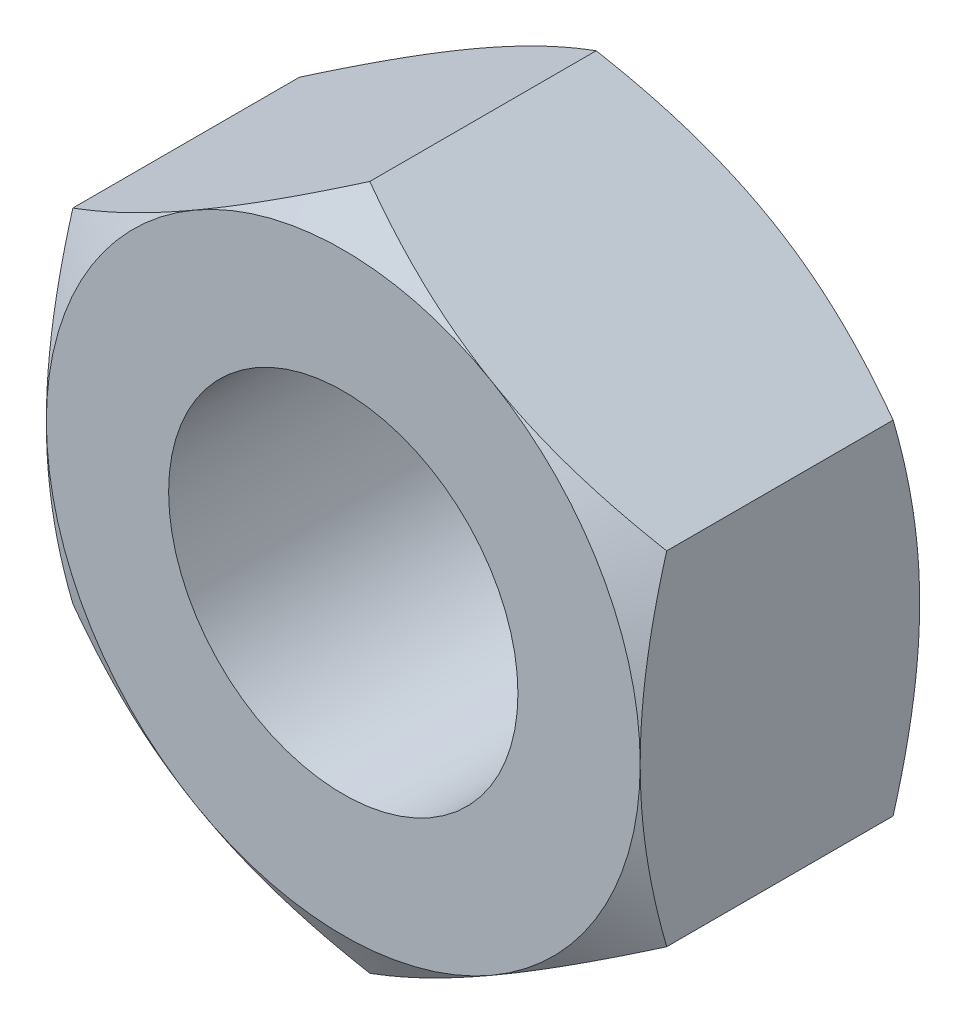
from build123d import *

# Parameters (mm, degrees)
EXTRUDE1_DEPTH          = 4
SKETCH13_R              = 5
BOSS_EXTRUDE1_DEPTH     = 8
SKETCH7_OUTSIDE_W       = 112.422
SKETCH7_OUTSIDE_H       = 115.052
SKETCH7_OUTSIDE_R       = 8.5
EXTRUDE2_DEPTH          = 25.4
EXTRUDE2_DRAFT          = -60
MIRROR2_COPY_1_SKETCH_W = 112.422
MIRROR2_COPY_1_SKETCH_H = 115.052
MIRROR2_COPY_1_SKETCH_R = 8.5
MIRROR2_COPY_1_DEPTH    = 25.4
MIRROR2_COPY_1_DRAFT    = -60


with BuildPart() as part:
    # Sketch1 → Extrude1 (new, symmetric)
    with BuildSketch(Plane.XY):
        Polygon((-8.5, 4.907477288), (-8.5, -4.907477288), (0, -9.814954576), (8.5, -4.907477288), (8.5, 4.907477288), (0, 9.814954576), align=None)
    extrude(amount=EXTRUDE1_DEPTH, both=True)

    # Cut-Extrude2 cone 1 section (through the dimple's axis) → Cut-Extrude2 (revolve, cut)
    with BuildSketch(Plane(origin=(0, 0, 4), x_dir=(0, -1, 0), z_dir=(1, 0, 0))):
        Polygon((0, 0), (5, 0), (0, 5), align=None)
    revolve(axis=Axis((0, 0, 4), (0, 0, -1)), mode=Mode.SUBTRACT)

    # Cut-Extrude3 cone 1 section (through the dimple's axis) → Cut-Extrude3 (revolve, cut)
    with BuildSketch(Plane(origin=(0, 0, -4), x_dir=(0, 1, 0), z_dir=(1, 0, 0))):
        Polygon((0, 0), (5, 0), (0, 5), align=None)
    revolve(axis=Axis((0, 0, -4), (0, 0, 1)), mode=Mode.SUBTRACT)


with BuildPart() as body_2:
    # Sketch13 → Boss-Extrude1 (new body)
    with BuildSketch(Plane(origin=(0, 0, -4), x_dir=(-1, 0, 0), z_dir=(0, 0, -1))):
        Circle(SKETCH13_R)
    extrude(amount=-BOSS_EXTRUDE1_DEPTH)


with BuildPart() as part_1:
    add(part.part)

    # Combine1: cut body 2
    add(body_2.part, mode=Mode.SUBTRACT)


with BuildPart() as extrude2_tool:
    # Sketch7 outside → Extrude2 (with draft: the straight prism first)
    with BuildSketch(Plane.XY.offset(4)):
        Rectangle(SKETCH7_OUTSIDE_W, SKETCH7_OUTSIDE_H)
        Circle(SKETCH7_OUTSIDE_R, mode=Mode.SUBTRACT)
    extrude(amount=-EXTRUDE2_DEPTH)
    # Extrude2: the draft: its side faces are tilted about the plane it starts from
    extrude2_sides = [extrude2_tool.faces().sort_by_distance(p)[0] for p in [
        (0, -57.526, -8.7),
        (56.211, 0, -8.7),
        (0, 57.526, -8.7),
        (-56.211, 0, -8.7),
        (-8.5, 0, -8.7),
    ]]
    draft(extrude2_sides, Plane.XY.offset(4), EXTRUDE2_DRAFT)


with BuildPart() as part_2:
    add(part_1.part)

    # Extrude2: cut by extrude2_tool
    add(extrude2_tool.part, mode=Mode.SUBTRACT)


with BuildPart() as mirror2_copy_1_tool:
    # Mirror2 copy 1 sketch → Mirror2 copy 1 (with draft: the straight prism first)
    with BuildSketch(Plane(origin=(0, 0, -4), x_dir=(1, 0, 0), z_dir=(0, 0, -1))):
        Rectangle(MIRROR2_COPY_1_SKETCH_W, MIRROR2_COPY_1_SKETCH_H)
        Circle(MIRROR2_COPY_1_SKETCH_R, mode=Mode.SUBTRACT)
    extrude(amount=-MIRROR2_COPY_1_DEPTH)
    # Mirror2 copy 1: the draft: its side faces are tilted about the plane it starts from
    mirror2_copy_1_sides = [mirror2_copy_1_tool.faces().sort_by_distance(p)[0] for p in [
        (0, -57.526, 8.7),
        (56.211, 0, 8.7),
        (0, 57.526, 8.7),
        (-56.211, 0, 8.7),
        (-8.5, 0, 8.7),
    ]]
    draft(mirror2_copy_1_sides, Plane(origin=(0, 0, -4), x_dir=(1, 0, 0), z_dir=(0, 0, -1)), MIRROR2_COPY_1_DRAFT)


with BuildPart() as part_3:
    add(part_2.part)

    # Mirror2 copy 1: cut by mirror2_copy_1_tool
    add(mirror2_copy_1_tool.part, mode=Mode.SUBTRACT)


solid = part_3.part
